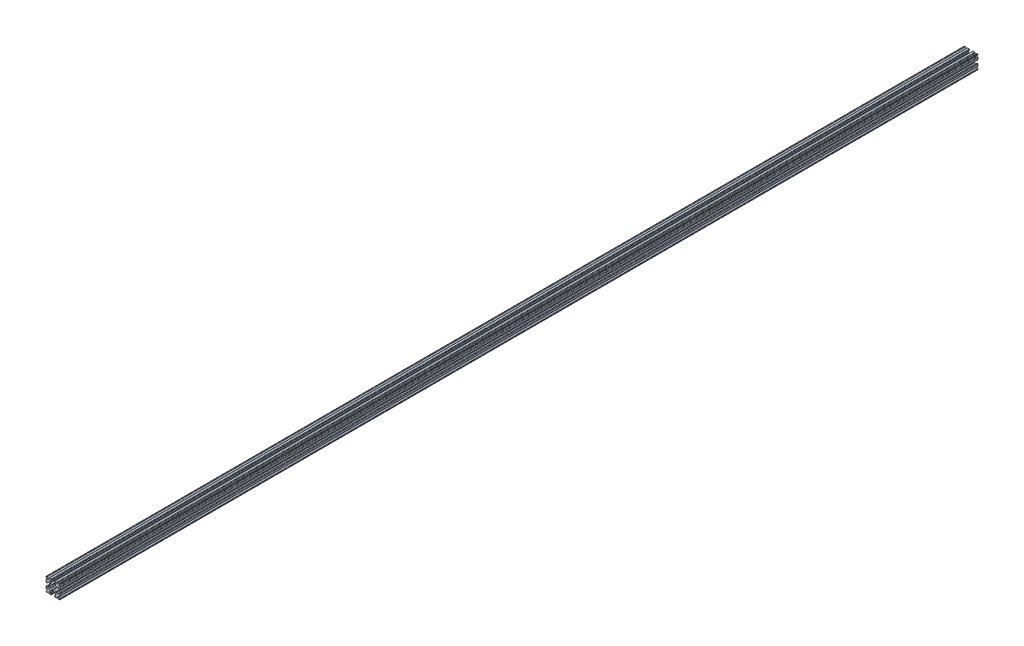
from build123d import *

# Parameters (mm, degrees)
RESSALTO_EXTRUS_O1_DEPTH = 25400
ESCALA2_SCALE            = 0.039370079


with BuildPart() as part:
    # Model → Ressalto-extrusão1 (new body)
    with BuildSketch(Plane.XY):
        with BuildLine():
            Line((53.34, -190.5), (99.06, -190.5))
            ThreePointArc((99.06, -190.5), (108.040256121, -186.780256121), (111.76, -177.8))
            Line((111.76, -177.8), (111.76, -169.361280606))
            ThreePointArc((111.76, -169.361280606), (119.599920409, -157.628010543), (133.440256121, -160.381024485))
            Line((133.440256121, -160.381024485), (159.839487758, -186.780256121))
            ThreePointArc((159.839487758, -186.780256121), (163.959664287, -189.533270063), (168.819743878, -190.5))
            Line((168.819743878, -190.5), (184.15, -190.5))
            ThreePointArc((184.15, -190.5), (188.640128061, -188.640128061), (190.5, -184.15))
            Line((190.5, -184.15), (190.5, -168.819743879))
            ThreePointArc((190.5, -168.819743879), (189.533270063, -163.959664288), (186.780256121, -159.839487757))
            Line((186.780256121, -159.839487757), (160.381024485, -133.440256121))
            ThreePointArc((160.381024485, -133.440256121), (157.628010543, -119.599920409), (169.361280606, -111.76))
            Line((169.361280606, -111.76), (177.8, -111.76))
            ThreePointArc((177.8, -111.76), (186.780256121, -108.040256121), (190.5, -99.06))
            Line((190.5, -99.06), (190.5, -53.34))
            ThreePointArc((190.5, -53.34), (186.780256121, -44.359743879), (177.8, -40.64))
            Line((177.8, -40.64), (167.64, -40.64))
            ThreePointArc((167.64, -40.64), (158.659743879, -44.359743879), (154.94, -53.34))
            Line((154.94, -53.34), (154.94, -68.58))
            ThreePointArc((154.94, -68.58), (153.452102448, -72.172102448), (149.86, -73.66))
            Line((149.86, -73.66), (96.528549378, -73.66))
            ThreePointArc((96.528549378, -73.66), (88.590853582, -70.873777557), (84.13602175, -63.737635504))
            Line((84.13602175, -63.737635504), (80.232585577, -46.32230488))
            Line((80.232585577, -46.32230488), (33.450700665, -19.312771034))
            ThreePointArc((33.450700665, -19.312771034), (28.393528602, -18.394640312), (23.903790859, -20.896681138))
            ThreePointArc((23.903790859, -20.896681138), (-31.75, 0), (23.903790859, 20.896681138))
            ThreePointArc((23.903790859, 20.896681138), (28.393528602, 18.394640312), (33.450700665, 19.312771034))
            Line((33.450700665, 19.312771034), (80.232585577, 46.322304881))
            Line((80.232585577, 46.322304881), (84.136021751, 63.737635503))
            ThreePointArc((84.136021751, 63.737635503), (88.590853582, 70.873777556), (96.528549378, 73.66))
            Line((96.528549378, 73.66), (149.86, 73.66))
            ThreePointArc((149.86, 73.66), (153.452102448, 72.172102448), (154.94, 68.58))
            Line((154.94, 68.58), (154.94, 53.34))
            ThreePointArc((154.94, 53.34), (158.659743879, 44.359743879), (167.64, 40.64))
            Line((167.64, 40.64), (177.8, 40.64))
            ThreePointArc((177.8, 40.64), (186.780256121, 44.359743879), (190.5, 53.34))
            Line((190.5, 53.34), (190.5, 99.06))
            ThreePointArc((190.5, 99.06), (186.780256121, 108.040256121), (177.8, 111.76))
            Line((177.8, 111.76), (169.361280606, 111.76))
            ThreePointArc((169.361280606, 111.76), (157.628010543, 119.599920409), (160.381024485, 133.440256121))
            Line((160.381024485, 133.440256121), (186.780256121, 159.839487758))
            ThreePointArc((186.780256121, 159.839487758), (189.533270063, 163.959664287), (190.5, 168.819743878))
            Line((190.5, 168.819743878), (190.5, 184.15))
            ThreePointArc((190.5, 184.15), (188.640128061, 188.640128061), (184.15, 190.5))
            Line((184.15, 190.5), (168.819743879, 190.5))
            ThreePointArc((168.819743879, 190.5), (163.959664288, 189.533270063), (159.839487757, 186.780256121))
            Line((159.839487757, 186.780256121), (133.440256121, 160.381024485))
            ThreePointArc((133.440256121, 160.381024485), (119.59992041, 157.628010543), (111.76, 169.361280604))
            Line((111.76, 169.361280604), (111.76, 177.8))
            ThreePointArc((111.76, 177.8), (108.040256121, 186.780256121), (99.06, 190.5))
            Line((99.06, 190.5), (53.34, 190.5))
            ThreePointArc((53.34, 190.5), (44.359743879, 186.780256121), (40.64, 177.8))
            Line((40.64, 177.8), (40.64, 167.64))
            ThreePointArc((40.64, 167.64), (44.359743879, 158.659743879), (53.34, 154.94))
            Line((53.34, 154.94), (68.58, 154.94))
            ThreePointArc((68.58, 154.94), (72.172102448, 153.452102448), (73.66, 149.86))
            Line((73.66, 149.86), (73.66, 96.528549379))
            ThreePointArc((73.66, 96.528549379), (70.873777556, 88.590853582), (63.737635501, 84.13602175))
            Line((63.737635501, 84.13602175), (24.936645798, 75.439248197))
            ThreePointArc((24.936645798, 75.439248197), (22.082188977, 73.657315464), (20.9677, 70.482237146))
            Line((20.9677, 70.482237146), (20.9677, 64.695440848))
            ThreePointArc((20.9677, 64.695440848), (19.479802448, 61.103338399), (15.8877, 59.615440848))
            Line((15.8877, 59.615440848), (-15.8877, 59.615440848))
            ThreePointArc((-15.8877, 59.615440848), (-19.479802448, 61.103338399), (-20.9677, 64.695440848))
            Line((-20.9677, 64.695440848), (-20.9677, 70.482237145))
            ThreePointArc((-20.9677, 70.482237145), (-22.082188977, 73.657315464), (-24.936645799, 75.439248197))
            Line((-24.936645799, 75.439248197), (-63.737635503, 84.13602175))
            ThreePointArc((-63.737635503, 84.13602175), (-70.873777557, 88.590853582), (-73.66, 96.528549378))
            Line((-73.66, 96.528549378), (-73.66, 149.86))
            ThreePointArc((-73.66, 149.86), (-72.172102448, 153.452102448), (-68.58, 154.94))
            Line((-68.58, 154.94), (-53.34, 154.94))
            ThreePointArc((-53.34, 154.94), (-44.359743879, 158.659743879), (-40.64, 167.64))
            Line((-40.64, 167.64), (-40.64, 177.8))
            ThreePointArc((-40.64, 177.8), (-44.359743879, 186.780256121), (-53.34, 190.5))
            Line((-53.34, 190.5), (-99.06, 190.5))
            ThreePointArc((-99.06, 190.5), (-108.040256121, 186.780256121), (-111.76, 177.8))
            Line((-111.76, 177.8), (-111.76, 169.361280606))
            ThreePointArc((-111.76, 169.361280606), (-119.599920409, 157.628010543), (-133.440256121, 160.381024485))
            Line((-133.440256121, 160.381024485), (-159.839487758, 186.780256121))
            ThreePointArc((-159.839487758, 186.780256121), (-163.959664287, 189.533270063), (-168.819743878, 190.5))
            Line((-168.819743878, 190.5), (-184.15, 190.5))
            ThreePointArc((-184.15, 190.5), (-188.640128061, 188.640128061), (-190.5, 184.15))
            Line((-190.5, 184.15), (-190.5, 168.819743879))
            ThreePointArc((-190.5, 168.819743879), (-189.533270063, 163.959664288), (-186.780256121, 159.839487757))
            Line((-186.780256121, 159.839487757), (-160.381024485, 133.440256121))
            ThreePointArc((-160.381024485, 133.440256121), (-157.628010543, 119.599920409), (-169.361280606, 111.76))
            Line((-169.361280606, 111.76), (-177.8, 111.76))
            ThreePointArc((-177.8, 111.76), (-186.780256121, 108.040256121), (-190.5, 99.06))
            Line((-190.5, 99.06), (-190.5, 53.34))
            ThreePointArc((-190.5, 53.34), (-186.780256121, 44.359743879), (-177.8, 40.64))
            Line((-177.8, 40.64), (-167.64, 40.64))
            ThreePointArc((-167.64, 40.64), (-158.659743879, 44.359743879), (-154.94, 53.34))
            Line((-154.94, 53.34), (-154.94, 68.58))
            ThreePointArc((-154.94, 68.58), (-153.452102448, 72.172102448), (-149.86, 73.66))
            Line((-149.86, 73.66), (-96.528549379, 73.66))
            ThreePointArc((-96.528549379, 73.66), (-88.590853582, 70.873777556), (-84.13602175, 63.737635501))
            Line((-84.13602175, 63.737635501), (-75.439248197, 24.936645798))
            ThreePointArc((-75.439248197, 24.936645798), (-73.657315464, 22.082188977), (-70.482237145, 20.9677))
            Line((-70.482237145, 20.9677), (-64.69544085, 20.9677))
            ThreePointArc((-64.69544085, 20.9677), (-61.103338402, 19.479802448), (-59.61544085, 15.8877))
            Line((-59.61544085, 15.8877), (-59.61544085, -15.8877))
            ThreePointArc((-59.61544085, -15.8877), (-61.103338402, -19.479802448), (-64.69544085, -20.9677))
            Line((-64.69544085, -20.9677), (-70.482237145, -20.9677))
            ThreePointArc((-70.482237145, -20.9677), (-73.657315464, -22.082188977), (-75.439248197, -24.936645799))
            Line((-75.439248197, -24.936645799), (-84.13602175, -63.737635503))
            ThreePointArc((-84.13602175, -63.737635503), (-88.590853582, -70.873777557), (-96.528549378, -73.66))
            Line((-96.528549378, -73.66), (-149.86, -73.66))
            ThreePointArc((-149.86, -73.66), (-153.452102448, -72.172102448), (-154.94, -68.58))
            Line((-154.94, -68.58), (-154.94, -53.34))
            ThreePointArc((-154.94, -53.34), (-158.659743879, -44.359743879), (-167.64, -40.64))
            Line((-167.64, -40.64), (-177.8, -40.64))
            ThreePointArc((-177.8, -40.64), (-186.780256121, -44.359743879), (-190.5, -53.34))
            Line((-190.5, -53.34), (-190.5, -99.06))
            ThreePointArc((-190.5, -99.06), (-186.780256121, -108.040256121), (-177.8, -111.76))
            Line((-177.8, -111.76), (-169.361280606, -111.76))
            ThreePointArc((-169.361280606, -111.76), (-157.628010543, -119.599920409), (-160.381024485, -133.440256121))
            Line((-160.381024485, -133.440256121), (-186.780256121, -159.839487758))
            ThreePointArc((-186.780256121, -159.839487758), (-189.533270063, -163.959664287), (-190.5, -168.819743878))
            Line((-190.5, -168.819743878), (-190.5, -184.15))
            ThreePointArc((-190.5, -184.15), (-188.640128061, -188.640128061), (-184.15, -190.5))
            Line((-184.15, -190.5), (-168.819743879, -190.5))
            ThreePointArc((-168.819743879, -190.5), (-163.959664288, -189.533270063), (-159.839487757, -186.780256121))
            Line((-159.839487757, -186.780256121), (-133.440256121, -160.381024485))
            ThreePointArc((-133.440256121, -160.381024485), (-119.599920409, -157.628010543), (-111.76, -169.361280606))
            Line((-111.76, -169.361280606), (-111.76, -177.8))
            ThreePointArc((-111.76, -177.8), (-108.040256121, -186.780256121), (-99.06, -190.5))
            Line((-99.06, -190.5), (-53.34, -190.5))
            ThreePointArc((-53.34, -190.5), (-44.359743879, -186.780256121), (-40.64, -177.8))
            Line((-40.64, -177.8), (-40.64, -167.64))
            ThreePointArc((-40.64, -167.64), (-44.359743879, -158.659743879), (-53.34, -154.94))
            Line((-53.34, -154.94), (-68.58, -154.94))
            ThreePointArc((-68.58, -154.94), (-72.172102448, -153.452102448), (-73.66, -149.86))
            Line((-73.66, -149.86), (-73.66, -96.528549378))
            ThreePointArc((-73.66, -96.528549378), (-70.873777557, -88.590853582), (-63.737635504, -84.13602175))
            Line((-63.737635504, -84.13602175), (-24.936645798, -75.439248197))
            ThreePointArc((-24.936645798, -75.439248197), (-22.082188977, -73.657315464), (-20.9677, -70.482237145))
            Line((-20.9677, -70.482237145), (-20.9677, -64.69544085))
            ThreePointArc((-20.9677, -64.69544085), (-19.479802448, -61.103338402), (-15.8877, -59.61544085))
            Line((-15.8877, -59.61544085), (15.8877, -59.61544085))
            ThreePointArc((15.8877, -59.61544085), (19.479802448, -61.103338402), (20.9677, -64.69544085))
            Line((20.9677, -64.69544085), (20.9677, -70.482237145))
            ThreePointArc((20.9677, -70.482237145), (22.082188977, -73.657315464), (24.936645799, -75.439248197))
            Line((24.936645799, -75.439248197), (63.737635503, -84.136021751))
            ThreePointArc((63.737635503, -84.136021751), (70.873777556, -88.590853582), (73.66, -96.528549378))
            Line((73.66, -96.528549378), (73.66, -149.86))
            ThreePointArc((73.66, -149.86), (72.172102448, -153.452102448), (68.58, -154.94))
            Line((68.58, -154.94), (53.34, -154.94))
            ThreePointArc((53.34, -154.94), (44.359743879, -158.659743879), (40.64, -167.64))
            Line((40.64, -167.64), (40.64, -177.8))
            ThreePointArc((40.64, -177.8), (44.359743879, -186.780256121), (53.34, -190.5))
        make_face()
    extrude(amount=RESSALTO_EXTRUS_O1_DEPTH)


with BuildPart() as part_1:
    # Escala2: scaled about (0, 0, 0)
    add(part.part.scale(ESCALA2_SCALE))


solid = part_1.part
